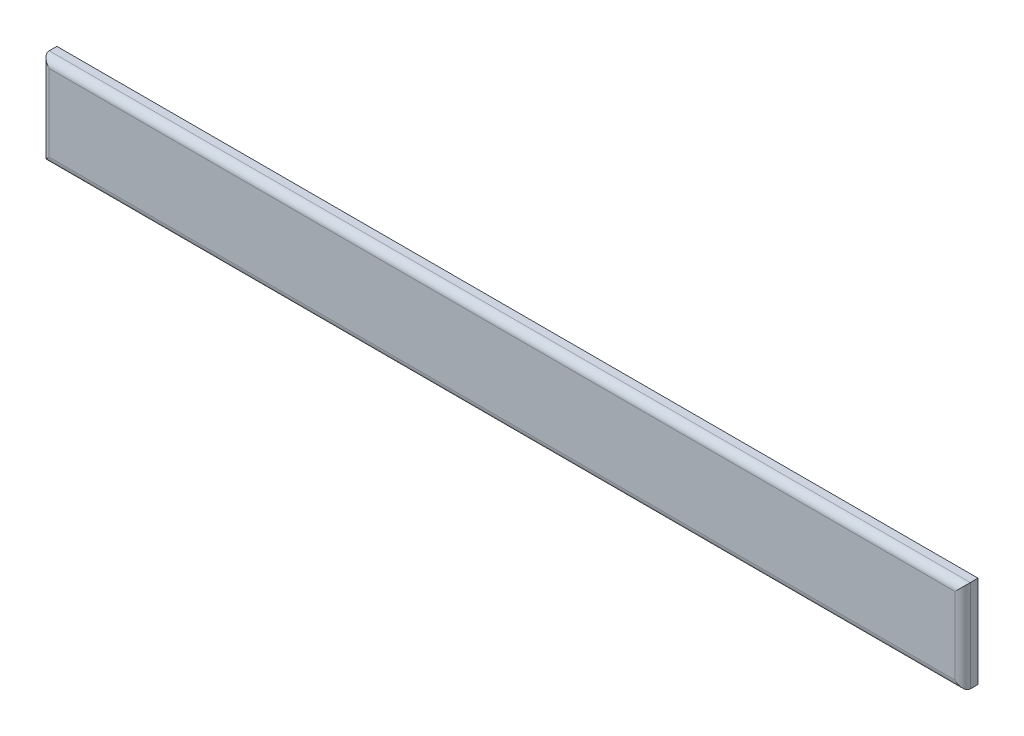
from build123d import *

# Parameters (mm, degrees)
SKETCH1_W           = 6000
SKETCH1_H           = 600
BOSS_EXTRUDE1_DEPTH = 100
FILLET1_R           = 50


with BuildPart() as part:
    # Sketch1 → Boss-Extrude1 (new body)
    with BuildSketch(Plane.XY):
        Rectangle(SKETCH1_W, SKETCH1_H)
    extrude(amount=-BOSS_EXTRUDE1_DEPTH)

    # Fillet1
    fillet1_edges = [part.edges().sort_by_distance(p)[0] for p in [
        (0, -300, 0),
        (-3000, 0, 0),
        (0, 300, 0),
        (3000, 0, 0),
    ]]
    fillet(fillet1_edges, radius=FILLET1_R)


solid = part.part
